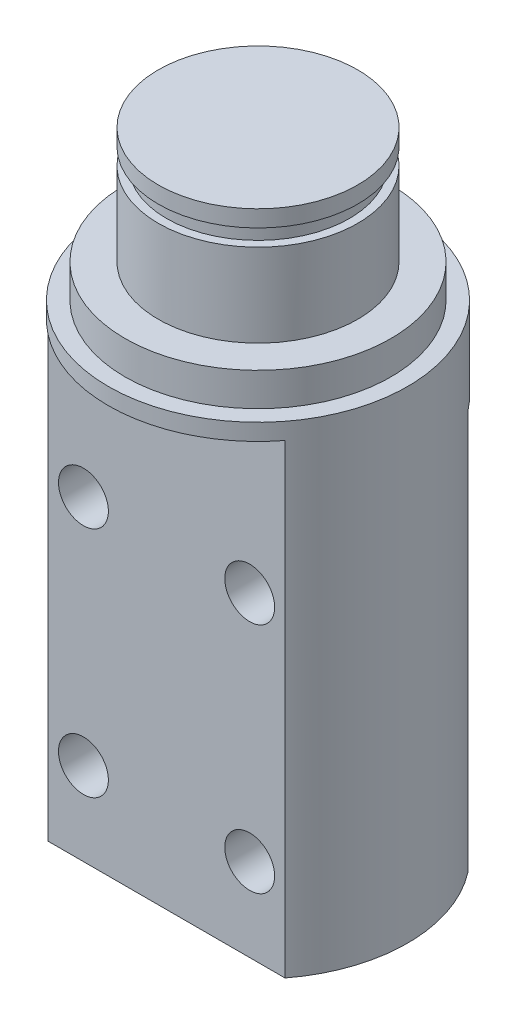
from build123d import *

# Parameters (mm, degrees)
SKETCH_1_R          = 6
EXTRUDE_1_DEPTH     = 7
SKETCH_2_R          = 9
EXTRUDE_2_DEPTH     = 31
SKETCH_3_W          = 19.613357353
SKETCH_3_H          = 3.5
CUT_EXTRUDE_1_DEPTH = 24
SKETCH_4_W          = 20.018720859
SKETCH_4_H          = 3.5
CUT_EXTRUDE_2_DEPTH = 28
SKETCH_5_R          = 1.5
CUT_EXTRUDE_3_DEPTH = 18
SKETCH_11_R         = 10.638163441
SKETCH_11_R_2       = 5.5
CUT_EXTRUDE_4_DEPTH = 1
SKETCH_12_R         = 9
SKETCH_12_R_2       = 8
CUT_EXTRUDE_7_DEPTH = 2


with BuildPart() as part:
    # 草图1 → 凸台-拉伸1 (new body)
    with BuildSketch(Plane(origin=(0, 0, 0), x_dir=(1, 0, 0), z_dir=(0, 1, 0))):
        Circle(SKETCH_1_R)
    extrude(amount=EXTRUDE_1_DEPTH)

    # 草图2 → 凸台-拉伸2 (add)
    with BuildSketch(Plane.XZ):
        Circle(SKETCH_2_R)
    extrude(amount=EXTRUDE_2_DEPTH)

    # 草图3 → 切除-拉伸1 (cut)
    with BuildSketch(Plane.XZ.offset(31)):
        with Locations((1.075772383, -7.25)):
            Rectangle(SKETCH_3_W, SKETCH_3_H)
    extrude(amount=-CUT_EXTRUDE_1_DEPTH, mode=Mode.SUBTRACT)

    # 草图4 → 切除-拉伸2 (cut)
    with BuildSketch(Plane.XZ.offset(31)):
        with Locations((1.37199956, 7.25)):
            Rectangle(SKETCH_4_W, SKETCH_4_H)
    extrude(amount=-CUT_EXTRUDE_2_DEPTH, mode=Mode.SUBTRACT)

    # 草图5 → 切除-拉伸3 (cut)
    with BuildSketch(Plane(origin=(0, 0, -5.5), x_dir=(-1, 0, 0), z_dir=(0, 0, -1))):
        with Locations((-5, -26)):
            Circle(SKETCH_5_R)
        with Locations((5, -26)):
            Circle(SKETCH_5_R)
        with Locations((5, -12)):
            Circle(SKETCH_5_R)
        with Locations((-5, -12)):
            Circle(SKETCH_5_R)
    extrude(amount=-CUT_EXTRUDE_3_DEPTH, mode=Mode.SUBTRACT)

    # 草图11 → 切除-拉伸4 (cut)
    with BuildSketch(Plane(origin=(0, 6, 0), x_dir=(1, 0, 0), z_dir=(0, 1, 0))):
        Circle(SKETCH_11_R)
        Circle(SKETCH_11_R_2, mode=Mode.SUBTRACT)
    extrude(amount=-CUT_EXTRUDE_4_DEPTH, mode=Mode.SUBTRACT)

    # 草图12 → 切除-拉伸7 (cut)
    with BuildSketch(Plane(origin=(0, 0, 0), x_dir=(1, 0, 0), z_dir=(0, 1, 0))):
        Circle(SKETCH_12_R)
        Circle(SKETCH_12_R_2, mode=Mode.SUBTRACT)
    extrude(amount=-CUT_EXTRUDE_7_DEPTH, mode=Mode.SUBTRACT)


solid = part.part
